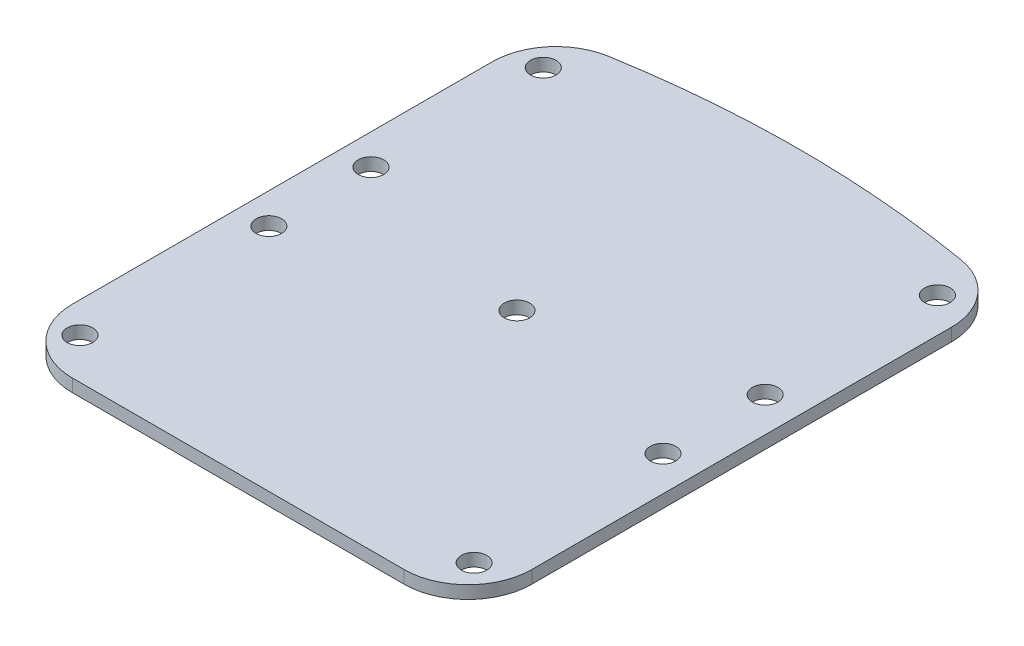
from build123d import *

# Parameters (mm, degrees)
BOSS_EXTRUDE1_DEPTH = 5
SKETCH5_R           = 5
CUT_EXTRUDE2_DEPTH  = 10


with BuildPart() as part:
    # Sketch1 → Boss-Extrude1 (new body)
    with BuildSketch(Plane(origin=(0, 0, 0), x_dir=(1, 0, 0), z_dir=(0, 1, 0))):
        with BuildLine():
            ThreePointArc((-89.202352286, -85), (-81.880021816, -102.67766953), (-64.202352286, -110))
            Line((-64.202352286, -110), (65.797647714, -110))
            ThreePointArc((65.797647714, -110), (83.475317244, -102.67766953), (90.797647714, -85))
            Line((90.797647714, -85), (90.797647714, -35))
            Line((90.797647714, -35), (90.797647714, 31.47331922))
            Line((90.797647714, 31.47331922), (90.797647714, 79.461679372))
            ThreePointArc((90.797647714, 79.461679372), (84.910138891, 95.577283021), (70.020633234, 104.102425978))
            ThreePointArc((70.020633234, 104.102425978), (0.80038099, 109.994179998), (-68.420925207, 104.11482166))
            ThreePointArc((-68.420925207, 104.11482166), (-83.313400439, 95.590634086), (-89.202352286, 79.47331922))
            Line((-89.202352286, 79.47331922), (-89.202352286, 31.47331922))
            Line((-89.202352286, 31.47331922), (-89.202352286, -35))
            Line((-89.202352286, -35), (-89.202352286, -85))
        make_face()
    extrude(amount=BOSS_EXTRUDE1_DEPTH)

    # Sketch5 → Cut-Extrude2 (cut)
    with BuildSketch(Plane(origin=(0, 5, 0), x_dir=(1, 0, 0), z_dir=(0, 1, 0))):
        with Locations((-77.202352286, 20)):
            Circle(SKETCH5_R)
        with Locations((-77.202352286, -20)):
            Circle(SKETCH5_R)
        with Locations((-77.202352286, 87.5)):
            Circle(SKETCH5_R)
        with Locations((-77.202352286, -94)):
            Circle(SKETCH5_R)
        Circle(SKETCH5_R)
        with Locations((77.202352286, -94)):
            Circle(SKETCH5_R)
        with Locations((77.202352286, -20)):
            Circle(SKETCH5_R)
        with Locations((77.202352286, 20)):
            Circle(SKETCH5_R)
        with Locations((77.202352286, 87.5)):
            Circle(SKETCH5_R)
    extrude(amount=-CUT_EXTRUDE2_DEPTH, mode=Mode.SUBTRACT)


solid = part.part
